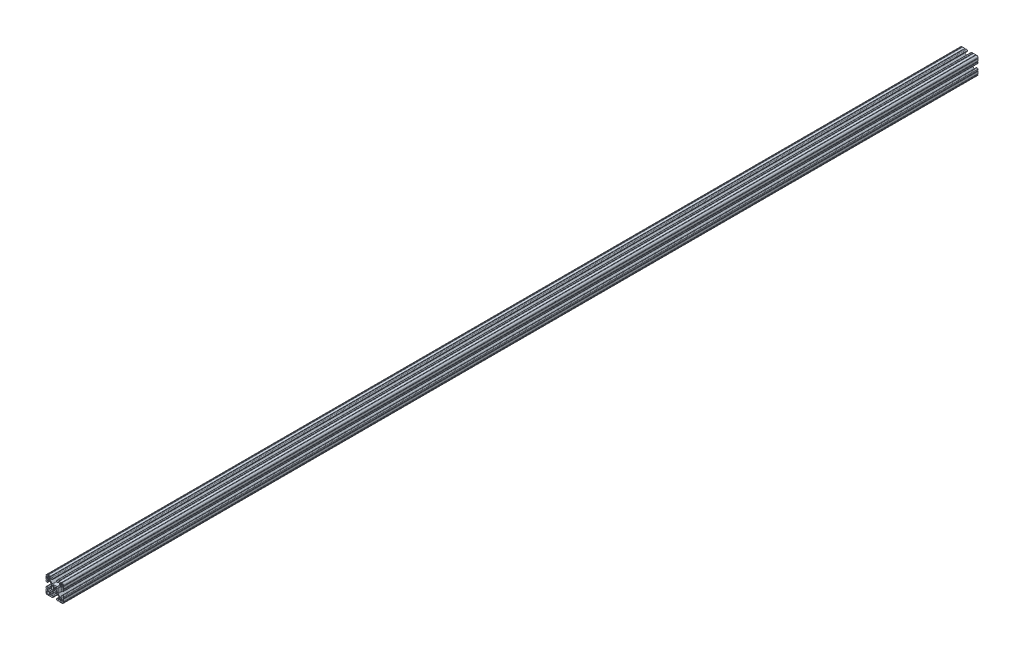
from build123d import *

# Parameters (mm, degrees)
EXTRUDE1_DEPTH = 1981.2


with BuildPart() as part:
    # Sketch1 → Extrude1 (new body)
    with BuildSketch(Plane.XY):
        with BuildLine():
            Line((6.349777007, -14.984831919), (5.653061318, -14.984831848))
            ThreePointArc((5.653061318, -14.984831848), (4.539002167, -15.446080098), (4.077754017, -16.560139291))
            Line((4.077754017, -16.560139291), (4.077753935, -17.474692556))
            ThreePointArc((4.077753935, -17.474692556), (4.539002158, -18.588751741), (5.653061362, -19.049999918))
            Line((5.653061362, -19.049999918), (7.975599859, -19.05))
            ThreePointArc((7.975599859, -19.05), (8.737599929, -18.288), (9.4996, -19.05))
            Line((9.4996, -19.05), (14.298091988, -19.05))
            ThreePointArc((14.298091988, -19.05), (15.05987163, -18.288000032), (15.822092002, -19.049559142))
            ThreePointArc((15.822092002, -19.049559142), (18.110316678, -18.129769245), (19.049898398, -15.849599993))
            ThreePointArc((19.049898398, -15.849599993), (18.288000002, -15.087549199), (19.05, -14.3256))
            Line((19.05, -14.3256), (19.05, -9.499600141))
            ThreePointArc((19.05, -9.499600141), (18.288, -8.737600071), (19.05, -7.9756))
            Line((19.05, -7.9756), (19.05, -5.653061359))
            ThreePointArc((19.05, -5.653061359), (18.588751763, -4.53900218), (17.474692553, -4.077754017))
            Line((17.474692553, -4.077754017), (16.560139293, -4.077753935))
            ThreePointArc((16.560139293, -4.077753935), (15.446080122, -4.539002143), (14.98483193, -5.653061321))
            Line((14.98483193, -5.653061321), (14.984831848, -6.349776986))
            ThreePointArc((14.984831848, -6.349776986), (15.096428348, -6.619420887), (15.366075744, -6.731008942))
            Line((15.366075744, -6.731008942), (15.696937609, -6.730998691))
            ThreePointArc((15.696937609, -6.730998691), (15.966583472, -6.842585282), (16.078181438, -7.112226438))
            Line((16.078181438, -7.112226438), (16.078207121, -9.396837814))
            ThreePointArc((16.078207121, -9.396837814), (15.817838504, -10.026619018), (15.188068118, -10.287013801))
            Line((15.188068118, -10.287013801), (12.352560476, -10.287103022))
            ThreePointArc((12.352560476, -10.287103022), (11.865894357, -10.190173629), (11.453520834, -9.914153164))
            Line((11.453520834, -9.914153164), (7.114725376, -5.565926641))
            ThreePointArc((7.114725376, -5.565926641), (6.840134749, -5.154247475), (6.7437254, -4.668876499))
            Line((6.7437254, -4.668876499), (6.7437254, 4.641368628))
            ThreePointArc((6.7437254, 4.641368628), (6.840134749, 5.126739605), (7.114725376, 5.53841877))
            Line((7.114725376, 5.53841877), (11.480968187, 9.914152308))
            ThreePointArc((11.480968187, 9.914152308), (11.89334171, 10.190172773), (12.380007829, 10.287102166))
            Line((12.380007829, 10.287102166), (15.188068116, 10.287014567))
            ThreePointArc((15.188068116, 10.287014567), (15.817838279, 10.026619243), (16.078206356, 9.396837815))
            Line((16.078206356, 9.396837815), (16.078181509, 7.1122265))
            ThreePointArc((16.078181509, 7.1122265), (15.966583514, 6.842585324), (15.696937607, 6.730998762))
            Line((15.696937607, 6.730998762), (15.366075744, 6.731009012))
            ThreePointArc((15.366075744, 6.731009012), (15.096428376, 6.619420915), (14.984831919, 6.349777007))
            Line((14.984831919, 6.349777007), (14.984831848, 5.653061318))
            ThreePointArc((14.984831848, 5.653061318), (15.446080098, 4.539002167), (16.560139291, 4.077754017))
            Line((16.560139291, 4.077754017), (17.474692556, 4.077753935))
            ThreePointArc((17.474692556, 4.077753935), (18.588751741, 4.539002158), (19.049999918, 5.653061362))
            Line((19.049999918, 5.653061362), (19.05, 7.975599859))
            ThreePointArc((19.05, 7.975599859), (18.288, 8.737599929), (19.05, 9.4996))
            Line((19.05, 9.4996), (19.05, 14.298091988))
            ThreePointArc((19.05, 14.298091988), (18.288000032, 15.05987163), (19.049559142, 15.822092002))
            ThreePointArc((19.049559142, 15.822092002), (18.129769245, 18.110316678), (15.849599993, 19.049898398))
            ThreePointArc((15.849599993, 19.049898398), (15.087549199, 18.288000002), (14.3256, 19.05))
            Line((14.3256, 19.05), (9.499600141, 19.05))
            ThreePointArc((9.499600141, 19.05), (8.737600071, 18.288), (7.9756, 19.05))
            Line((7.9756, 19.05), (5.653061359, 19.05))
            ThreePointArc((5.653061359, 19.05), (4.53900218, 18.588751763), (4.077754017, 17.474692553))
            Line((4.077754017, 17.474692553), (4.077753935, 16.560139293))
            ThreePointArc((4.077753935, 16.560139293), (4.539002143, 15.446080122), (5.653061321, 14.98483193))
            Line((5.653061321, 14.98483193), (6.349776986, 14.984831848))
            ThreePointArc((6.349776986, 14.984831848), (6.619420887, 15.096428348), (6.731008942, 15.366075744))
            Line((6.731008942, 15.366075744), (6.730998691, 15.696937609))
            ThreePointArc((6.730998691, 15.696937609), (6.842585282, 15.966583472), (7.112226438, 16.078181438))
            Line((7.112226438, 16.078181438), (9.396837814, 16.078207121))
            ThreePointArc((9.396837814, 16.078207121), (10.026619018, 15.817838504), (10.287013801, 15.188068118))
            Line((10.287013801, 15.188068118), (10.287103022, 12.352560476))
            ThreePointArc((10.287103022, 12.352560476), (10.190173629, 11.865894357), (9.914153164, 11.453520834))
            Line((9.914153164, 11.453520834), (5.565926641, 7.114725376))
            ThreePointArc((5.565926641, 7.114725376), (5.154247475, 6.840134749), (4.668876499, 6.7437254))
            Line((4.668876499, 6.7437254), (-4.641368628, 6.7437254))
            ThreePointArc((-4.641368628, 6.7437254), (-5.126739605, 6.840134749), (-5.53841877, 7.114725376))
            Line((-5.53841877, 7.114725376), (-9.914152308, 11.480968187))
            ThreePointArc((-9.914152308, 11.480968187), (-10.190172773, 11.89334171), (-10.287102166, 12.380007829))
            Line((-10.287102166, 12.380007829), (-10.287014567, 15.188068116))
            ThreePointArc((-10.287014567, 15.188068116), (-10.026619243, 15.817838279), (-9.396837815, 16.078206356))
            Line((-9.396837815, 16.078206356), (-7.1122265, 16.078181509))
            ThreePointArc((-7.1122265, 16.078181509), (-6.842585324, 15.966583514), (-6.730998762, 15.696937607))
            Line((-6.730998762, 15.696937607), (-6.731008942, 15.366075744))
            ThreePointArc((-6.731008942, 15.366075744), (-6.619420905, 15.096428366), (-6.349777007, 14.984831919))
            Line((-6.349777007, 14.984831919), (-5.653061318, 14.984831848))
            ThreePointArc((-5.653061318, 14.984831848), (-4.539002167, 15.446080098), (-4.077754017, 16.560139291))
            Line((-4.077754017, 16.560139291), (-4.077753935, 17.474692556))
            ThreePointArc((-4.077753935, 17.474692556), (-4.539002158, 18.588751741), (-5.653061362, 19.049999918))
            Line((-5.653061362, 19.049999918), (-7.975599859, 19.05))
            ThreePointArc((-7.975599859, 19.05), (-8.737599929, 18.288), (-9.4996, 19.05))
            Line((-9.4996, 19.05), (-14.298091988, 19.05))
            ThreePointArc((-14.298091988, 19.05), (-15.05987163, 18.288000032), (-15.822092002, 19.049559142))
            ThreePointArc((-15.822092002, 19.049559142), (-18.110316678, 18.129769245), (-19.049898398, 15.849599993))
            ThreePointArc((-19.049898398, 15.849599993), (-18.288000002, 15.087549199), (-19.05, 14.3256))
            Line((-19.05, 14.3256), (-19.05, 9.499600141))
            ThreePointArc((-19.05, 9.499600141), (-18.288, 8.737600071), (-19.05, 7.9756))
            Line((-19.05, 7.9756), (-19.05, 5.653061359))
            ThreePointArc((-19.05, 5.653061359), (-18.588751763, 4.53900218), (-17.474692553, 4.077754017))
            Line((-17.474692553, 4.077754017), (-16.560139293, 4.077753935))
            ThreePointArc((-16.560139293, 4.077753935), (-15.446080122, 4.539002143), (-14.98483193, 5.653061321))
            Line((-14.98483193, 5.653061321), (-14.984831848, 6.349776986))
            ThreePointArc((-14.984831848, 6.349776986), (-15.096428348, 6.619420887), (-15.366075744, 6.731008942))
            Line((-15.366075744, 6.731008942), (-15.696937609, 6.730998691))
            ThreePointArc((-15.696937609, 6.730998691), (-15.966583472, 6.842585283), (-16.078181438, 7.112226438))
            Line((-16.078181438, 7.112226438), (-16.078207121, 9.396837814))
            ThreePointArc((-16.078207121, 9.396837814), (-15.817838504, 10.026619018), (-15.188068118, 10.287013802))
            Line((-15.188068118, 10.287013802), (-12.352560476, 10.287103022))
            ThreePointArc((-12.352560476, 10.287103022), (-11.865894357, 10.190173629), (-11.453520834, 9.914153164))
            Line((-11.453520834, 9.914153164), (-7.114725376, 5.565926641))
            ThreePointArc((-7.114725376, 5.565926641), (-6.840134749, 5.154247475), (-6.7437254, 4.668876499))
            Line((-6.7437254, 4.668876499), (-6.7437254, -4.641368628))
            ThreePointArc((-6.7437254, -4.641368628), (-6.840134749, -5.126739605), (-7.114725376, -5.53841877))
            Line((-7.114725376, -5.53841877), (-11.480968187, -9.914152308))
            ThreePointArc((-11.480968187, -9.914152308), (-11.89334171, -10.190172773), (-12.380007829, -10.287102166))
            Line((-12.380007829, -10.287102166), (-15.188068116, -10.287014567))
            ThreePointArc((-15.188068116, -10.287014567), (-15.817838279, -10.026619243), (-16.078206356, -9.396837815))
            Line((-16.078206356, -9.396837815), (-16.078181509, -7.1122265))
            ThreePointArc((-16.078181509, -7.1122265), (-15.966583514, -6.842585324), (-15.696937607, -6.730998762))
            Line((-15.696937607, -6.730998762), (-15.366075744, -6.731009012))
            ThreePointArc((-15.366075744, -6.731009012), (-15.096428376, -6.619420915), (-14.984831919, -6.349777007))
            Line((-14.984831919, -6.349777007), (-14.984831848, -5.653061318))
            ThreePointArc((-14.984831848, -5.653061318), (-15.446080098, -4.539002167), (-16.560139291, -4.077754017))
            Line((-16.560139291, -4.077754017), (-17.474692556, -4.077753935))
            ThreePointArc((-17.474692556, -4.077753935), (-18.588751741, -4.539002158), (-19.049999918, -5.653061362))
            Line((-19.049999918, -5.653061362), (-19.05, -7.975599859))
            ThreePointArc((-19.05, -7.975599859), (-18.288, -8.737599929), (-19.05, -9.4996))
            Line((-19.05, -9.4996), (-19.05, -14.298091988))
            ThreePointArc((-19.05, -14.298091988), (-18.288000032, -15.05987163), (-19.049559142, -15.822092002))
            ThreePointArc((-19.049559142, -15.822092002), (-18.129769245, -18.110316678), (-15.849599993, -19.049898398))
            ThreePointArc((-15.849599993, -19.049898398), (-15.087549199, -18.288000002), (-14.3256, -19.05))
            Line((-14.3256, -19.05), (-9.499600141, -19.05))
            ThreePointArc((-9.499600141, -19.05), (-8.737600071, -18.288), (-7.9756, -19.05))
            Line((-7.9756, -19.05), (-5.653061359, -19.05))
            ThreePointArc((-5.653061359, -19.05), (-4.53900218, -18.588751763), (-4.077754017, -17.474692553))
            Line((-4.077754017, -17.474692553), (-4.077753935, -16.560139293))
            ThreePointArc((-4.077753935, -16.560139293), (-4.539002143, -15.446080122), (-5.653061321, -14.98483193))
            Line((-5.653061321, -14.98483193), (-6.349776986, -14.984831848))
            ThreePointArc((-6.349776986, -14.984831848), (-6.619420887, -15.096428348), (-6.731008942, -15.366075744))
            Line((-6.731008942, -15.366075744), (-6.730998691, -15.696937609))
            ThreePointArc((-6.730998691, -15.696937609), (-6.842585282, -15.966583472), (-7.112226438, -16.078181438))
            Line((-7.112226438, -16.078181438), (-9.396837814, -16.078207121))
            ThreePointArc((-9.396837814, -16.078207121), (-10.026619018, -15.817838504), (-10.287013801, -15.188068118))
            Line((-10.287013801, -15.188068118), (-10.287103022, -12.352560476))
            ThreePointArc((-10.287103022, -12.352560476), (-10.190173629, -11.865894357), (-9.914153164, -11.453520834))
            Line((-9.914153164, -11.453520834), (-5.565926641, -7.114725376))
            ThreePointArc((-5.565926641, -7.114725376), (-5.154247475, -6.840134749), (-4.668876499, -6.7437254))
            Line((-4.668876499, -6.7437254), (4.641368628, -6.7437254))
            ThreePointArc((4.641368628, -6.7437254), (5.126739605, -6.840134749), (5.53841877, -7.114725376))
            Line((5.53841877, -7.114725376), (9.914152308, -11.480968187))
            ThreePointArc((9.914152308, -11.480968187), (10.190172773, -11.89334171), (10.287102166, -12.380007829))
            Line((10.287102166, -12.380007829), (10.287014567, -15.188068116))
            ThreePointArc((10.287014567, -15.188068116), (10.026619243, -15.817838279), (9.396837815, -16.078206356))
            Line((9.396837815, -16.078206356), (7.1122265, -16.078181509))
            ThreePointArc((7.1122265, -16.078181509), (6.842585324, -15.966583514), (6.730998762, -15.696937607))
            Line((6.730998762, -15.696937607), (6.731008942, -15.366075744))
            ThreePointArc((6.731008942, -15.366075744), (6.619420905, -15.096428366), (6.349777007, -14.984831919))
        make_face()
        with BuildLine():
            Line((1.582347442, 3.198793543), (3.292097227, 4.908543328))
            ThreePointArc((3.292097227, 4.908543328), (3.580509584, 5.101254304), (3.920715155, 5.1689254))
            Line((3.920715155, 5.1689254), (4.9149254, 5.1689254))
            ThreePointArc((4.9149254, 5.1689254), (5.094530522, 5.094530522), (5.1689254, 4.9149254))
            Line((5.1689254, 4.9149254), (5.1689254, 3.920715155))
            ThreePointArc((5.1689254, 3.920715155), (5.101254304, 3.580509584), (4.908543328, 3.292097227))
            Line((4.908543328, 3.292097227), (3.198793543, 1.582347442))
            ThreePointArc((3.198793543, 1.582347442), (3.095711236, 1.393016011), (3.111879183, 1.178048687))
            ThreePointArc((3.111879183, 1.178048687), (3.3274, 0), (3.111879183, -1.178048687))
            ThreePointArc((3.111879183, -1.178048687), (3.095711236, -1.393016011), (3.198793543, -1.582347442))
            Line((3.198793543, -1.582347442), (4.908543328, -3.292097227))
            ThreePointArc((4.908543328, -3.292097227), (5.101254304, -3.580509584), (5.1689254, -3.920715155))
            Line((5.1689254, -3.920715155), (5.1689254, -4.9149254))
            ThreePointArc((5.1689254, -4.9149254), (5.094530522, -5.094530522), (4.9149254, -5.1689254))
            Line((4.9149254, -5.1689254), (3.920715155, -5.1689254))
            ThreePointArc((3.920715155, -5.1689254), (3.580509584, -5.101254304), (3.292097227, -4.908543328))
            Line((3.292097227, -4.908543328), (1.582347442, -3.198793543))
            ThreePointArc((1.582347442, -3.198793543), (1.393016011, -3.095711236), (1.178048687, -3.111879183))
            ThreePointArc((1.178048687, -3.111879183), (0, -3.3274), (-1.178048687, -3.111879183))
            ThreePointArc((-1.178048687, -3.111879183), (-1.393016011, -3.095711236), (-1.582347442, -3.198793543))
            Line((-1.582347442, -3.198793543), (-3.292097227, -4.908543328))
            ThreePointArc((-3.292097227, -4.908543328), (-3.580509584, -5.101254304), (-3.920715155, -5.1689254))
            Line((-3.920715155, -5.1689254), (-4.9149254, -5.1689254))
            ThreePointArc((-4.9149254, -5.1689254), (-5.094530522, -5.094530522), (-5.1689254, -4.9149254))
            Line((-5.1689254, -4.9149254), (-5.1689254, -3.920715155))
            ThreePointArc((-5.1689254, -3.920715155), (-5.101254304, -3.580509584), (-4.908543328, -3.292097227))
            Line((-4.908543328, -3.292097227), (-3.198793543, -1.582347442))
            ThreePointArc((-3.198793543, -1.582347442), (-3.095711236, -1.393016011), (-3.111879183, -1.178048687))
            ThreePointArc((-3.111879183, -1.178048687), (-3.3274, 0), (-3.111879183, 1.178048687))
            ThreePointArc((-3.111879183, 1.178048687), (-3.095711236, 1.393016011), (-3.198793543, 1.582347442))
            Line((-3.198793543, 1.582347442), (-4.908543328, 3.292097227))
            ThreePointArc((-4.908543328, 3.292097227), (-5.101254304, 3.580509584), (-5.1689254, 3.920715155))
            Line((-5.1689254, 3.920715155), (-5.1689254, 4.9149254))
            ThreePointArc((-5.1689254, 4.9149254), (-5.094530522, 5.094530522), (-4.9149254, 5.1689254))
            Line((-4.9149254, 5.1689254), (-3.920715155, 5.1689254))
            ThreePointArc((-3.920715155, 5.1689254), (-3.580509584, 5.101254304), (-3.292097227, 4.908543328))
            Line((-3.292097227, 4.908543328), (-1.582347442, 3.198793543))
            ThreePointArc((-1.582347442, 3.198793543), (-1.393016011, 3.095711236), (-1.178048687, 3.111879183))
            ThreePointArc((-1.178048687, 3.111879183), (0, 3.3274), (1.178048687, 3.111879183))
            ThreePointArc((1.178048687, 3.111879183), (1.393016011, 3.095711236), (1.582347442, 3.198793543))
        make_face(mode=Mode.SUBTRACT)
        with BuildLine():
            Line((-11.8669054, 14.019430433), (-11.8669054, 12.24788))
            ThreePointArc((-11.8669054, 12.24788), (-11.978497716, 11.978472316), (-12.2479054, 11.86688))
            Line((-12.2479054, 11.86688), (-14.019455833, 11.86688))
            ThreePointArc((-14.019455833, 11.86688), (-14.020427836, 11.867073341), (-14.021251865, 11.867623929))
            Line((-14.021251865, 11.867623929), (-14.557512425, 12.403872831))
            ThreePointArc((-14.557512425, 12.403872831), (-14.559308484, 12.404616761), (-14.561104527, 12.403872792))
            Line((-14.561104527, 12.403872792), (-15.097341694, 11.867623968))
            ThreePointArc((-15.097341694, 11.867623968), (-15.098165736, 11.867073351), (-15.099137765, 11.86688))
            Line((-15.099137765, 11.86688), (-16.8707054, 11.86688))
            ThreePointArc((-16.8707054, 11.86688), (-17.140113084, 11.978472316), (-17.2517054, 12.24788))
            Line((-17.2517054, 12.24788), (-17.2517054, 14.45768))
            ThreePointArc((-17.2517054, 14.45768), (-16.433361747, 16.433336347), (-14.4577054, 17.25168))
            Line((-14.4577054, 17.25168), (-12.2479054, 17.25168))
            ThreePointArc((-12.2479054, 17.25168), (-11.978497716, 17.140087684), (-11.8669054, 16.87068))
            Line((-11.8669054, 16.87068), (-11.8669054, 15.099112365))
            ThreePointArc((-11.8669054, 15.099112365), (-11.867098751, 15.098140336), (-11.867649368, 15.097316294))
            Line((-11.867649368, 15.097316294), (-12.403898192, 14.561079127))
            ThreePointArc((-12.403898192, 14.561079127), (-12.40464216, 14.559283084), (-12.403898231, 14.557487025))
            Line((-12.403898231, 14.557487025), (-11.867649329, 14.021226465))
            ThreePointArc((-11.867649329, 14.021226465), (-11.867098741, 14.020402437), (-11.8669054, 14.019430433))
        make_face(mode=Mode.SUBTRACT)
        with BuildLine():
            Line((-14.019430433, -11.8669054), (-12.24788, -11.8669054))
            ThreePointArc((-12.24788, -11.8669054), (-11.978472316, -11.978497716), (-11.86688, -12.2479054))
            Line((-11.86688, -12.2479054), (-11.86688, -14.019455833))
            ThreePointArc((-11.86688, -14.019455833), (-11.867073341, -14.020427836), (-11.867623929, -14.021251865))
            Line((-11.867623929, -14.021251865), (-12.403872831, -14.557512425))
            ThreePointArc((-12.403872831, -14.557512425), (-12.404616761, -14.559308484), (-12.403872792, -14.561104527))
            Line((-12.403872792, -14.561104527), (-11.867623968, -15.097341694))
            ThreePointArc((-11.867623968, -15.097341694), (-11.867073351, -15.098165736), (-11.86688, -15.099137765))
            Line((-11.86688, -15.099137765), (-11.86688, -16.8707054))
            ThreePointArc((-11.86688, -16.8707054), (-11.978472316, -17.140113083), (-12.24788, -17.2517054))
            Line((-12.24788, -17.2517054), (-14.45768, -17.2517054))
            ThreePointArc((-14.45768, -17.2517054), (-16.433336347, -16.433361746), (-17.25168, -14.4577054))
            Line((-17.25168, -14.4577054), (-17.25168, -12.2479054))
            ThreePointArc((-17.25168, -12.2479054), (-17.140087684, -11.978497716), (-16.87068, -11.8669054))
            Line((-16.87068, -11.8669054), (-15.099112365, -11.8669054))
            ThreePointArc((-15.099112365, -11.8669054), (-15.098140336, -11.867098751), (-15.097316294, -11.867649368))
            Line((-15.097316294, -11.867649368), (-14.561079127, -12.403898192))
            ThreePointArc((-14.561079127, -12.403898192), (-14.559283084, -12.40464216), (-14.557487025, -12.403898231))
            Line((-14.557487025, -12.403898231), (-14.021226465, -11.867649329))
            ThreePointArc((-14.021226465, -11.867649329), (-14.020402437, -11.867098741), (-14.019430433, -11.8669054))
        make_face(mode=Mode.SUBTRACT)
        with BuildLine():
            Line((11.8669054, -14.019430433), (11.8669054, -12.24788))
            ThreePointArc((11.8669054, -12.24788), (11.978497716, -11.978472316), (12.2479054, -11.86688))
            Line((12.2479054, -11.86688), (14.019455833, -11.86688))
            ThreePointArc((14.019455833, -11.86688), (14.020427836, -11.867073341), (14.021251865, -11.867623929))
            Line((14.021251865, -11.867623929), (14.557512425, -12.403872831))
            ThreePointArc((14.557512425, -12.403872831), (14.559308484, -12.404616761), (14.561104527, -12.403872792))
            Line((14.561104527, -12.403872792), (15.097341694, -11.867623968))
            ThreePointArc((15.097341694, -11.867623968), (15.098165736, -11.867073351), (15.099137765, -11.86688))
            Line((15.099137765, -11.86688), (16.8707054, -11.86688))
            ThreePointArc((16.8707054, -11.86688), (17.140113084, -11.978472316), (17.2517054, -12.24788))
            Line((17.2517054, -12.24788), (17.2517054, -14.45768))
            ThreePointArc((17.2517054, -14.45768), (16.433361747, -16.433336347), (14.4577054, -17.25168))
            Line((14.4577054, -17.25168), (12.2479054, -17.25168))
            ThreePointArc((12.2479054, -17.25168), (11.978497716, -17.140087684), (11.8669054, -16.87068))
            Line((11.8669054, -16.87068), (11.8669054, -15.099112365))
            ThreePointArc((11.8669054, -15.099112365), (11.867098751, -15.098140336), (11.867649368, -15.097316294))
            Line((11.867649368, -15.097316294), (12.403898192, -14.561079127))
            ThreePointArc((12.403898192, -14.561079127), (12.40464216, -14.559283084), (12.403898231, -14.557487025))
            Line((12.403898231, -14.557487025), (11.867649329, -14.021226465))
            ThreePointArc((11.867649329, -14.021226465), (11.867098741, -14.020402436), (11.8669054, -14.019430433))
        make_face(mode=Mode.SUBTRACT)
        with BuildLine():
            Line((14.019430433, 11.8669054), (12.24788, 11.8669054))
            ThreePointArc((12.24788, 11.8669054), (11.978472316, 11.978497716), (11.86688, 12.2479054))
            Line((11.86688, 12.2479054), (11.86688, 14.019455833))
            ThreePointArc((11.86688, 14.019455833), (11.867073341, 14.020427836), (11.867623929, 14.021251865))
            Line((11.867623929, 14.021251865), (12.403872831, 14.557512425))
            ThreePointArc((12.403872831, 14.557512425), (12.404616761, 14.559308484), (12.403872792, 14.561104527))
            Line((12.403872792, 14.561104527), (11.867623968, 15.097341694))
            ThreePointArc((11.867623968, 15.097341694), (11.867073351, 15.098165736), (11.86688, 15.099137765))
            Line((11.86688, 15.099137765), (11.86688, 16.8707054))
            ThreePointArc((11.86688, 16.8707054), (11.978472316, 17.140113084), (12.24788, 17.2517054))
            Line((12.24788, 17.2517054), (14.45768, 17.2517054))
            ThreePointArc((14.45768, 17.2517054), (16.433336347, 16.433361747), (17.25168, 14.4577054))
            Line((17.25168, 14.4577054), (17.25168, 12.2479054))
            ThreePointArc((17.25168, 12.2479054), (17.140087684, 11.978497716), (16.87068, 11.8669054))
            Line((16.87068, 11.8669054), (15.099112365, 11.8669054))
            ThreePointArc((15.099112365, 11.8669054), (15.098140336, 11.867098751), (15.097316294, 11.867649368))
            Line((15.097316294, 11.867649368), (14.561079127, 12.403898192))
            ThreePointArc((14.561079127, 12.403898192), (14.559283084, 12.404642161), (14.557487025, 12.403898231))
            Line((14.557487025, 12.403898231), (14.021226465, 11.867649329))
            ThreePointArc((14.021226465, 11.867649329), (14.020402436, 11.867098741), (14.019430433, 11.8669054))
        make_face(mode=Mode.SUBTRACT)
    extrude(amount=-EXTRUDE1_DEPTH)


solid = part.part
